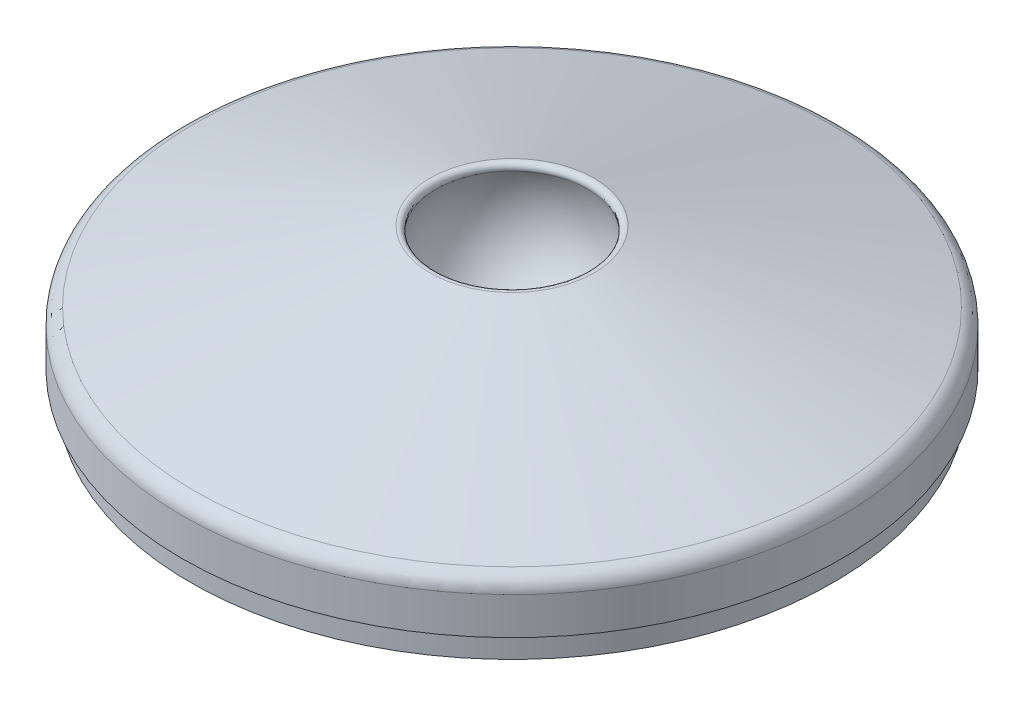
from build123d import *

# Parameters (mm, degrees)
FILLET1_R           = 0.3
SKETCH4_R           = 19.5
BOSS_EXTRUDE1_DEPTH = 1.5
FILLET2_R           = 1


with BuildPart() as part:
    # Sketch2 → Revolve1 (revolve)
    with BuildSketch(Plane.XY):
        Polygon((0, 0), (-20, 0), (-20, 3.004926108), (0, 9.014778325), align=None)
    revolve(axis=Axis((0, 35.024630542, 0), (0, -1, 0)))

    # Sketch3 → Cut-Revolve2 (revolve, cut)
    with BuildSketch(Plane.XY):
        with BuildLine():
            Line((0, 0.2), (0, 10.2))
            ThreePointArc((0, 10.2), (-5, 5.2), (0, 0.2))
        make_face()
    revolve(axis=Axis((0, 12.296737064, 0), (0, -1, 0)), mode=Mode.SUBTRACT)

    # Fillet1
    fillet1_edges = [part.edges().sort_by_distance(p)[0] for p in [
        (4.320571191, 7.716478608, 0),
    ]]
    fillet(fillet1_edges, radius=FILLET1_R)

    # Sketch4 → Boss-Extrude1 (add)
    with BuildSketch(Plane.XZ):
        Circle(SKETCH4_R)
    extrude(amount=BOSS_EXTRUDE1_DEPTH)

    # Fillet2
    fillet2_edges = [part.edges().sort_by_distance(p)[0] for p in [
        (20, 3.004926108, 0),
    ]]
    fillet(fillet2_edges, radius=FILLET2_R)


solid = part.part
